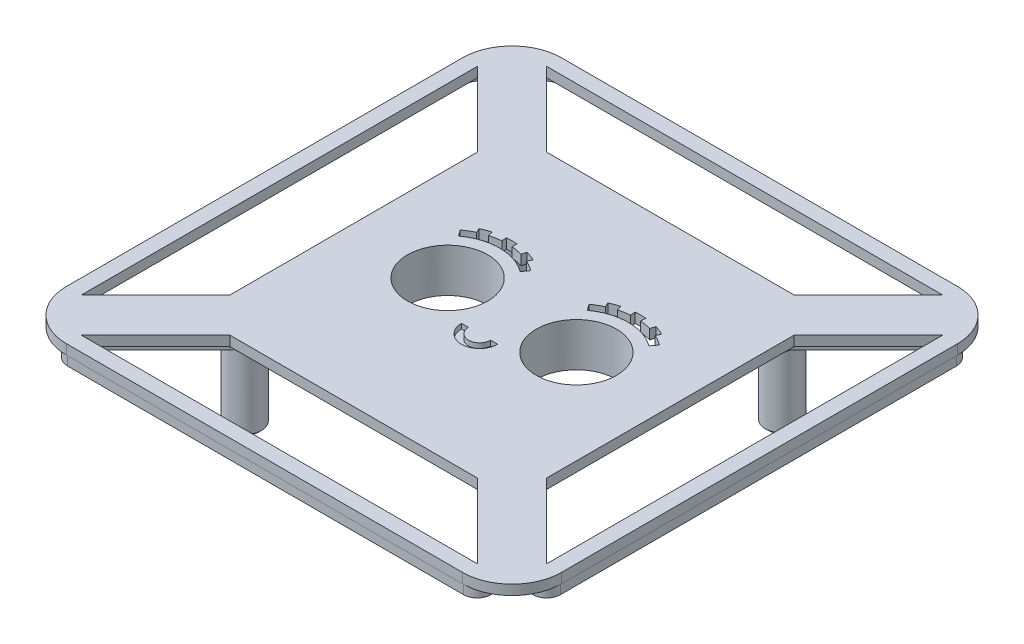
from build123d import *

# Parameters (mm, degrees)
SKETCH1_R                 = 8.1
BOSS_EXTRUDE1_DEPTH       = 2
BOSS_EXTRUDE2_DEPTH       = 2
BOSS_EXTRUDE3_START       = 6.8
SKETCH3_4_R               = 10.1
SKETCH3_4_R_2             = 8.1
BOSS_EXTRUDE3_DEPTH       = 6.8
CUT_EXTRUDE1_DEPTH        = 1
CHAMFER1_SIZE             = 1
SKETCH5_R                 = 3.385164807
SKETCH5_R_2               = 1.5
BOSS_EXTRUDE4_DEPTH       = 17
MIRROR2_COPY_1_SKETCH_R   = 3.385164807
MIRROR2_COPY_1_SKETCH_R_2 = 1.5
MIRROR2_COPY_1_DEPTH      = 17
MIRROR2_COPY_2_SKETCH_R   = 3.385164807
MIRROR2_COPY_2_SKETCH_R_2 = 1.5
MIRROR2_COPY_2_DEPTH      = 17
CHAMFER2_SIZE             = 0.5


with BuildPart() as part:
    # Sketch1 → Boss-Extrude1 (new body)
    with BuildSketch(Plane(origin=(0, 0, 0), x_dir=(1, 0, 0), z_dir=(0, 1, 0))):
        with BuildLine():
            Line((0, 90), (0, 50))
            Line((0, 50), (0, 10))
            ThreePointArc((0, 10), (2.928932188, 2.928932188), (10, 0))
            Line((10, 0), (90, 0))
            ThreePointArc((90, 0), (97.071067812, 2.928932188), (100, 10))
            Line((100, 10), (100, 90))
            ThreePointArc((100, 90), (97.071067812, 97.071067812), (90, 100))
            Line((90, 100), (10, 100))
            ThreePointArc((10, 100), (2.928932188, 97.071067812), (0, 90))
        make_face()
        Polygon((90, 3), (10, 3), (25, 18), (75, 18), align=None, mode=Mode.SUBTRACT)
        Polygon((3, 10), (3, 50), (3, 90), (18, 75), (18, 25), align=None, mode=Mode.SUBTRACT)
        with Locations((37, 50)):
            Circle(SKETCH1_R, mode=Mode.SUBTRACT)
        with BuildLine():
            ThreePointArc((43.216579907, 58.436381562), (37, 60.479427446), (30.783420093, 58.436381562))
            Line((30.783420093, 58.436381562), (29.881389821, 59.66050667))
            ThreePointArc((29.881389821, 59.66050667), (30.892954378, 60.329762523), (31.966911153, 60.893485056))
            Line((31.966911153, 60.893485056), (31.547487082, 61.801275477))
            ThreePointArc((31.547487082, 61.801275477), (32.492608022, 62.193580998), (33.465657647, 62.510332695))
            Line((33.465657647, 62.510332695), (33.737530136, 61.547999411))
            ThreePointArc((33.737530136, 61.547999411), (34.85476604, 61.8066918), (35.991594154, 61.957554836))
            Line((35.991594154, 61.957554836), (35.907560333, 62.954017739))
            ThreePointArc((35.907560333, 62.954017739), (37, 63), (38.092439667, 62.954017739))
            Line((38.092439667, 62.954017739), (38.008405846, 61.957554836))
            ThreePointArc((38.008405846, 61.957554836), (39.14523396, 61.8066918), (40.262469864, 61.547999411))
            Line((40.262469864, 61.547999411), (40.534342353, 62.510332695))
            ThreePointArc((40.534342353, 62.510332695), (41.507391978, 62.193580998), (42.452512918, 61.801275477))
            Line((42.452512918, 61.801275477), (42.033088847, 60.893485056))
            ThreePointArc((42.033088847, 60.893485056), (43.107045622, 60.329762523), (44.118610179, 59.66050667))
            Line((44.118610179, 59.66050667), (43.216579907, 58.436381562))
        make_face(mode=Mode.SUBTRACT)
        Polygon((25, 82), (10, 97), (90, 97), (75, 82), align=None, mode=Mode.SUBTRACT)
        with Locations((63, 50)):
            Circle(SKETCH1_R, mode=Mode.SUBTRACT)
        with BuildLine():
            ThreePointArc((55.881389821, 59.66050667), (56.892954378, 60.329762523), (57.966911153, 60.893485056))
            Line((57.966911153, 60.893485056), (57.547487082, 61.801275477))
            ThreePointArc((57.547487082, 61.801275477), (58.492608022, 62.193580998), (59.465657647, 62.510332695))
            Line((59.465657647, 62.510332695), (59.737530136, 61.547999411))
            ThreePointArc((59.737530136, 61.547999411), (60.85476604, 61.8066918), (61.991594154, 61.957554836))
            Line((61.991594154, 61.957554836), (61.907560333, 62.954017739))
            ThreePointArc((61.907560333, 62.954017739), (63, 63), (64.092439667, 62.954017739))
            Line((64.092439667, 62.954017739), (64.008405846, 61.957554836))
            ThreePointArc((64.008405846, 61.957554836), (65.14523396, 61.8066918), (66.262469864, 61.547999411))
            Line((66.262469864, 61.547999411), (66.534342353, 62.510332695))
            ThreePointArc((66.534342353, 62.510332695), (67.507391978, 62.193580998), (68.452512918, 61.801275477))
            Line((68.452512918, 61.801275477), (68.033088847, 60.893485056))
            ThreePointArc((68.033088847, 60.893485056), (69.107045622, 60.329762523), (70.118610179, 59.66050667))
            Line((70.118610179, 59.66050667), (69.216579907, 58.436381562))
            ThreePointArc((69.216579907, 58.436381562), (63, 60.479427446), (56.783420093, 58.436381562))
            Line((56.783420093, 58.436381562), (55.881389821, 59.66050667))
        make_face(mode=Mode.SUBTRACT)
        Polygon((97, 90), (97, 10), (82, 25), (82, 75), align=None, mode=Mode.SUBTRACT)
    extrude(amount=BOSS_EXTRUDE1_DEPTH)

    # Sketch3 → Boss-Extrude2 (add)
    # profile 1 of 4: a face of its own
    with BuildSketch(Plane.XZ):
        with BuildLine():
            ThreePointArc((99.8, -10), (98.071513611, -7.413137309), (95.020101013, -8.020101013))
            Line((95.020101013, -8.020101013), (80.020101013, -23.020101013))
            ThreePointArc((80.020101013, -23.020101013), (79.413137309, -23.928486389), (79.2, -25))
            Line((79.2, -25), (79.2, -75))
            ThreePointArc((79.2, -75), (79.413137309, -76.071513611), (80.020101013, -76.979898987))
            Line((80.020101013, -76.979898987), (95.020101013, -91.979898987))
            ThreePointArc((95.020101013, -91.979898987), (98.071513611, -92.586862691), (99.8, -90))
            Line((99.8, -90), (99.8, -10))
        make_face()
        with BuildLine():
            ThreePointArc((99, -90), (97.765366865, -91.847759065), (95.585786438, -91.414213562))
            Line((95.585786438, -91.414213562), (80.585786438, -76.414213562))
            ThreePointArc((80.585786438, -76.414213562), (80.152240935, -75.765366865), (80, -75))
            Line((80, -75), (80, -25))
            ThreePointArc((80, -25), (80.152240935, -24.234633135), (80.585786438, -23.585786438))
            Line((80.585786438, -23.585786438), (95.585786438, -8.585786438))
            ThreePointArc((95.585786438, -8.585786438), (97.765366865, -8.152240935), (99, -10))
            Line((99, -10), (99, -90))
        make_face(mode=Mode.SUBTRACT)
    # profile 2 of 4: a face of its own
    with BuildSketch(Plane.XZ):
        with BuildLine():
            ThreePointArc((90, -99.8), (92.586862691, -98.071513611), (91.979898987, -95.020101013))
            Line((91.979898987, -95.020101013), (76.979898987, -80.020101013))
            ThreePointArc((76.979898987, -80.020101013), (76.071513611, -79.413137309), (75, -79.2))
            Line((75, -79.2), (25, -79.2))
            ThreePointArc((25, -79.2), (23.928486389, -79.413137309), (23.020101013, -80.020101013))
            Line((23.020101013, -80.020101013), (8.020101013, -95.020101013))
            ThreePointArc((8.020101013, -95.020101013), (7.413137309, -98.071513611), (10, -99.8))
            Line((10, -99.8), (90, -99.8))
        make_face()
        with BuildLine():
            Line((90, -99), (10, -99))
            ThreePointArc((10, -99), (8.152240935, -97.765366865), (8.585786438, -95.585786438))
            Line((8.585786438, -95.585786438), (23.585786438, -80.585786438))
            ThreePointArc((23.585786438, -80.585786438), (24.234633135, -80.152240935), (25, -80))
            Line((25, -80), (75, -80))
            ThreePointArc((75, -80), (75.765366865, -80.152240935), (76.414213562, -80.585786438))
            Line((76.414213562, -80.585786438), (91.414213562, -95.585786438))
            ThreePointArc((91.414213562, -95.585786438), (91.847759065, -97.765366865), (90, -99))
        make_face(mode=Mode.SUBTRACT)
    # profile 3 of 4: a face of its own
    with BuildSketch(Plane.XZ):
        with BuildLine():
            ThreePointArc((4.979898987, -8.020101013), (1.928486389, -7.413137309), (0.2, -10))
            Line((0.2, -10), (0.2, -90))
            ThreePointArc((0.2, -90), (1.928486389, -92.586862691), (4.979898987, -91.979898987))
            Line((4.979898987, -91.979898987), (19.979898987, -76.979898987))
            ThreePointArc((19.979898987, -76.979898987), (20.586862691, -76.071513611), (20.8, -75))
            Line((20.8, -75), (20.8, -25))
            ThreePointArc((20.8, -25), (20.586862691, -23.928486389), (19.979898987, -23.020101013))
            Line((19.979898987, -23.020101013), (4.979898987, -8.020101013))
        make_face()
        with BuildLine():
            Line((19.414213562, -76.414213562), (4.414213562, -91.414213562))
            ThreePointArc((4.414213562, -91.414213562), (2.234633135, -91.847759065), (1, -90))
            Line((1, -90), (1, -10))
            ThreePointArc((1, -10), (2.234633135, -8.152240935), (4.414213562, -8.585786438))
            Line((4.414213562, -8.585786438), (19.414213562, -23.585786438))
            ThreePointArc((19.414213562, -23.585786438), (19.847759065, -24.234633135), (20, -25))
            Line((20, -25), (20, -75))
            ThreePointArc((20, -75), (19.847759065, -75.765366865), (19.414213562, -76.414213562))
        make_face(mode=Mode.SUBTRACT)
    # profile 4 of 4: a face of its own
    with BuildSketch(Plane.XZ):
        with BuildLine():
            ThreePointArc((10, -0.2), (7.413137309, -1.928486389), (8.020101013, -4.979898987))
            Line((8.020101013, -4.979898987), (23.020101013, -19.979898987))
            ThreePointArc((23.020101013, -19.979898987), (23.928486389, -20.586862691), (25, -20.8))
            Line((25, -20.8), (75, -20.8))
            ThreePointArc((75, -20.8), (76.071513611, -20.586862691), (76.979898987, -19.979898987))
            Line((76.979898987, -19.979898987), (91.979898987, -4.979898987))
            ThreePointArc((91.979898987, -4.979898987), (92.586862691, -1.928486389), (90, -0.2))
            Line((90, -0.2), (10, -0.2))
        make_face()
        with BuildLine():
            ThreePointArc((90, -1), (91.847759065, -2.234633135), (91.414213562, -4.414213562))
            Line((91.414213562, -4.414213562), (76.414213562, -19.414213562))
            ThreePointArc((76.414213562, -19.414213562), (75.765366865, -19.847759065), (75, -20))
            Line((75, -20), (25, -20))
            ThreePointArc((25, -20), (24.234633135, -19.847759065), (23.585786438, -19.414213562))
            Line((23.585786438, -19.414213562), (8.585786438, -4.414213562))
            ThreePointArc((8.585786438, -4.414213562), (8.152240935, -2.234633135), (10, -1))
            Line((10, -1), (90, -1))
        make_face(mode=Mode.SUBTRACT)
    extrude(amount=BOSS_EXTRUDE2_DEPTH)

    # Sketch3_4 → Boss-Extrude3 (add)
    # profile 1 of 2: a face of its own
    with BuildSketch(Plane.XZ.offset(BOSS_EXTRUDE3_START)):
        with Locations((63, -50)):
            Circle(SKETCH3_4_R)
        with Locations((63, -50)):
            Circle(SKETCH3_4_R_2, mode=Mode.SUBTRACT)
    # profile 2 of 2: a face of its own
    with BuildSketch(Plane.XZ.offset(BOSS_EXTRUDE3_START)):
        with Locations((37, -50)):
            Circle(SKETCH3_4_R)
        with Locations((37, -50)):
            Circle(SKETCH3_4_R_2, mode=Mode.SUBTRACT)
    extrude(amount=-BOSS_EXTRUDE3_DEPTH)

    # Sketch4 → Cut-Extrude1 (cut)
    with BuildSketch(Plane(origin=(0, 2, 0), x_dir=(1, 0, 0), z_dir=(0, 1, 0))):
        with BuildLine():
            Line((46.34101249, 43.452736805), (47.76390736, 43.452736805))
            ThreePointArc((47.76390736, 43.452736805), (50, 41.216644164), (52.23609264, 43.452736805))
            Line((52.23609264, 43.452736805), (53.65898751, 43.452736805))
            ThreePointArc((53.65898751, 43.452736805), (50, 39.793749294), (46.34101249, 43.452736805))
        make_face()
    extrude(amount=-CUT_EXTRUDE1_DEPTH, mode=Mode.SUBTRACT)

    # Chamfer1
    chamfer1_edges = [part.edges().sort_by_distance(p)[0] for p in [
        (26.9, -6.8, -50),
        (52.9, -6.8, -50),
    ]]
    chamfer(chamfer1_edges, length=CHAMFER1_SIZE)

    # Sketch5 → Boss-Extrude4 (add)
    with BuildSketch(Plane.XZ):
        with Locations((23, -23)):
            Circle(SKETCH5_R)
        with Locations((23, -23)):
            Circle(SKETCH5_R_2, mode=Mode.SUBTRACT)
    boss_extrude4 = extrude(amount=BOSS_EXTRUDE4_DEPTH)

    # Mirror1: Boss-Extrude4 across plane
    add(boss_extrude4.mirror(Plane(origin=(50, 0, 0), x_dir=(0, 0, 1), z_dir=(1, 0, 0))))

    # Mirror2 copy 1 sketch → Mirror2 copy 1 (add)
    with BuildSketch(Plane(origin=(100, 0, -100.572807955), x_dir=(-1, 0, 0), z_dir=(0, -1, 0))):
        with Locations((23, -23)):
            Circle(MIRROR2_COPY_1_SKETCH_R)
        with Locations((23, -23)):
            Circle(MIRROR2_COPY_1_SKETCH_R_2, mode=Mode.SUBTRACT)
    extrude(amount=MIRROR2_COPY_1_DEPTH)

    # Mirror2 copy 2 sketch → Mirror2 copy 2 (add)
    with BuildSketch(Plane(origin=(0, 0, -100.572807955), x_dir=(1, 0, 0), z_dir=(0, -1, 0))):
        with Locations((23, 23)):
            Circle(MIRROR2_COPY_2_SKETCH_R)
        with Locations((23, 23)):
            Circle(MIRROR2_COPY_2_SKETCH_R_2, mode=Mode.SUBTRACT)
    extrude(amount=MIRROR2_COPY_2_DEPTH)

    # Chamfer2
    chamfer2_edges = [part.edges().sort_by_distance(p)[0] for p in [
        (21.5, -17, -23),
        (19.614835193, -17, -23),
        (19.614835193, -17, -77.572807955),
        (21.5, -17, -77.572807955),
        (78.5, -17, -77.572807955),
        (80.385164807, -17, -77.572807955),
        (78.5, -17, -23),
        (80.385164807, -17, -23),
    ]]
    chamfer(chamfer2_edges, length=CHAMFER2_SIZE)


solid = part.part
